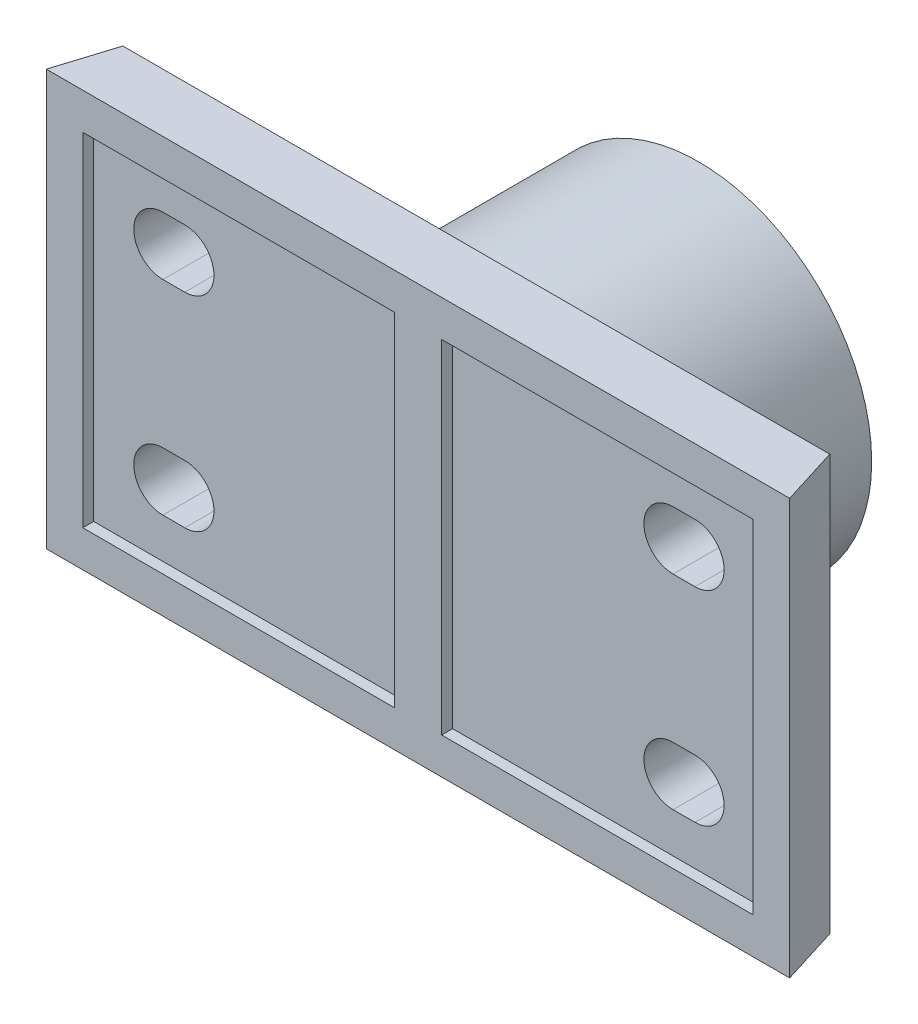
from build123d import *

# Parameters (mm, degrees)
BOSS_EXTRUDE1_DEPTH = 57
SKETCH3_R           = 47.5
SKETCH3_R_2         = 31
BOSS_EXTRUDE3_DEPTH = 13
SKETCH4_R           = 47.5
SKETCH4_R_2         = 32.5
BOSS_EXTRUDE4_DEPTH = 37
SKETCH5_R           = 47.5
SKETCH5_R_2         = 31
BOSS_EXTRUDE5_DEPTH = 11
SKETCH8_R           = 19
BOSS_EXTRUDE6_DEPTH = 3
SKETCH9_W           = 85.5
SKETCH9_H           = 94
CUT_EXTRUDE1_DEPTH  = 3
CUT_EXTRUDE3_DEPTH  = 29.5
CUT_EXTRUDE4_DEPTH  = 36


with BuildPart() as part:
    # Sketch1 → Boss-Extrude1 (new body, symmetric)
    with BuildSketch(Plane(origin=(0, 0, 0), x_dir=(1, 0, 0), z_dir=(0, 1, 0))):
        Polygon((-102, 0), (-97, 16), (97, 16), (102, 0), (0, 0), align=None)
    extrude(amount=BOSS_EXTRUDE1_DEPTH, both=True)

    # Sketch3 → Boss-Extrude3 (add)
    with BuildSketch(Plane(origin=(0, 0, -16), x_dir=(-1, 0, 0), z_dir=(0, 0, -1))):
        with Locations(Location((0, 0, 0), (0, 0, 180))):  # turned: the seam where the file's is
            Circle(SKETCH3_R)
        Circle(SKETCH3_R_2, mode=Mode.SUBTRACT)
    extrude(amount=BOSS_EXTRUDE3_DEPTH)

    # Sketch4 → Boss-Extrude4 (add)
    with BuildSketch(Plane(origin=(0, 0, -29), x_dir=(-1, 0, 0), z_dir=(0, 0, -1))):
        with Locations(Location((0, 0, 0), (0, 0, 180))):  # turned: the seam where the file's is
            Circle(SKETCH4_R)
        Circle(SKETCH4_R_2, mode=Mode.SUBTRACT)
    extrude(amount=BOSS_EXTRUDE4_DEPTH)

    # Sketch5 → Boss-Extrude5 (add)
    with BuildSketch(Plane(origin=(0, 0, -66), x_dir=(-1, 0, 0), z_dir=(0, 0, -1))):
        with Locations(Location((0, 0, 0), (0, 0, 180))):  # turned: the seam where the file's is
            Circle(SKETCH5_R)
        Circle(SKETCH5_R_2, mode=Mode.SUBTRACT)
    extrude(amount=BOSS_EXTRUDE5_DEPTH)

    # Sketch8 → Boss-Extrude6 (add)
    with BuildSketch(Plane(origin=(0, 0, -16), x_dir=(-1, 0, 0), z_dir=(0, 0, -1))):
        with Locations(Location((-70, 28, 0), (0, 0, 180))):  # turned: the seam where the file's is
            Circle(SKETCH8_R)
        with Locations(Location((-70, -28, 0), (0, 0, 180))):  # turned: the seam where the file's is
            Circle(SKETCH8_R)
    boss_extrude6 = extrude(amount=BOSS_EXTRUDE6_DEPTH)

    # Sketch9 → Cut-Extrude1 (cut)
    with BuildSketch(Plane.XY):
        with Locations((49.25, 0)):
            Rectangle(SKETCH9_W, SKETCH9_H)
    cut_extrude1 = extrude(amount=-CUT_EXTRUDE1_DEPTH, mode=Mode.SUBTRACT)

    # Sketch6 → Cut-Extrude3 (cut, symmetric)
    with BuildSketch(Plane(origin=(0, 0, -16), x_dir=(-1, 0, 0), z_dir=(0, 0, -1))):
        with BuildLine():
            Line((-73, 36), (-67, 36))
            ThreePointArc((-67, 36), (-59, 28), (-67, 20))
            Line((-67, 20), (-73, 20))
            ThreePointArc((-73, 20), (-81, 28), (-73, 36))
        make_face()
    cut_extrude3 = extrude(amount=CUT_EXTRUDE3_DEPTH, both=True, mode=Mode.SUBTRACT)

    # Sketch7 → Cut-Extrude4 (cut, symmetric)
    with BuildSketch(Plane(origin=(0, 0, -16), x_dir=(-1, 0, 0), z_dir=(0, 0, -1))):
        with BuildLine():
            Line((-73, -20), (-67, -20))
            ThreePointArc((-67, -20), (-59, -28), (-67, -36))
            Line((-67, -36), (-73, -36))
            ThreePointArc((-73, -36), (-81, -28), (-73, -20))
        make_face()
    cut_extrude4 = extrude(amount=CUT_EXTRUDE4_DEPTH, both=True, mode=Mode.SUBTRACT)

    # Mirror1: Boss-Extrude6, Cut-Extrude1, Cut-Extrude3, Cut-Extrude4 across plane
    add(boss_extrude6.mirror(Plane(origin=(0, 0, 0), x_dir=(0, 0, 1), z_dir=(1, 0, 0))))
    add(cut_extrude1.mirror(Plane(origin=(0, 0, 0), x_dir=(0, 0, 1), z_dir=(1, 0, 0))), mode=Mode.SUBTRACT)
    add(cut_extrude3.mirror(Plane(origin=(0, 0, 0), x_dir=(0, 0, 1), z_dir=(1, 0, 0))), mode=Mode.SUBTRACT)
    add(cut_extrude4.mirror(Plane(origin=(0, 0, 0), x_dir=(0, 0, 1), z_dir=(1, 0, 0))), mode=Mode.SUBTRACT)


solid = part.part
